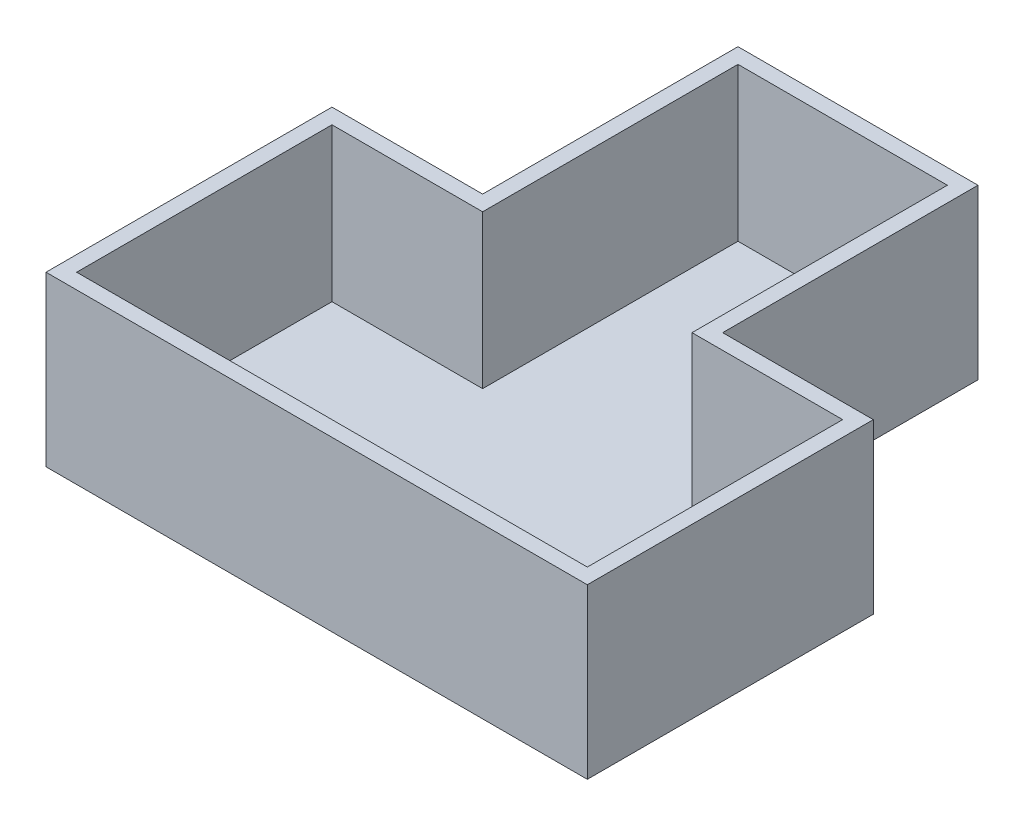
from build123d import *

# Parameters (mm, degrees)
BOSS_EXTRUDE1_DEPTH = 30
SHELL1_T            = 3


with BuildPart() as part:
    # Sketch1 → Boss-Extrude1 (new body)
    with BuildSketch(Plane(origin=(0, 0, 0), x_dir=(1, 0, 0), z_dir=(0, 1, 0))):
        Polygon((20.5, 48.994047619), (-20.5, 48.994047619), (-20.5, -1.005952381), (-50, -1.005952381), (-50, -51.005952381), (50, -51.005952381), (50, -1.005952381), (20.5, -1.005952381), align=None)
    extrude(amount=BOSS_EXTRUDE1_DEPTH)

    # Shell1
    shell1_openings = [part.faces().sort_by_distance(p)[0] for p in [
        (0, 30, 11.466945289),
    ]]
    offset(amount=SHELL1_T, openings=shell1_openings, kind=Kind.INTERSECTION)


solid = part.part
